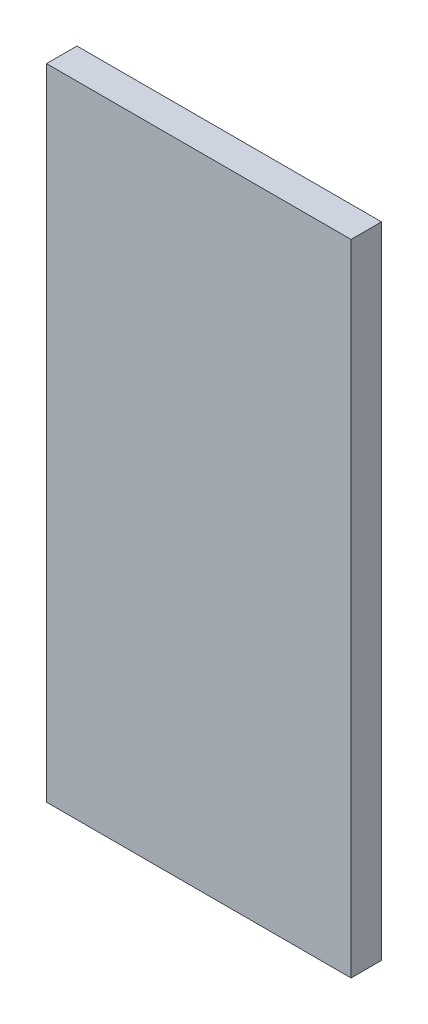
from build123d import *

# Parameters (mm, degrees)
CROQUIS1_W              = 1000
CROQUIS1_H              = 2100
SALIENTE_EXTRUIR1_DEPTH = 100


with BuildPart() as part:
    # Croquis1 → Saliente-Extruir1 (new body)
    with BuildSketch(Plane.XY):
        with Locations((500, -1050)):
            Rectangle(CROQUIS1_W, CROQUIS1_H)
    extrude(amount=SALIENTE_EXTRUIR1_DEPTH)


solid = part.part
